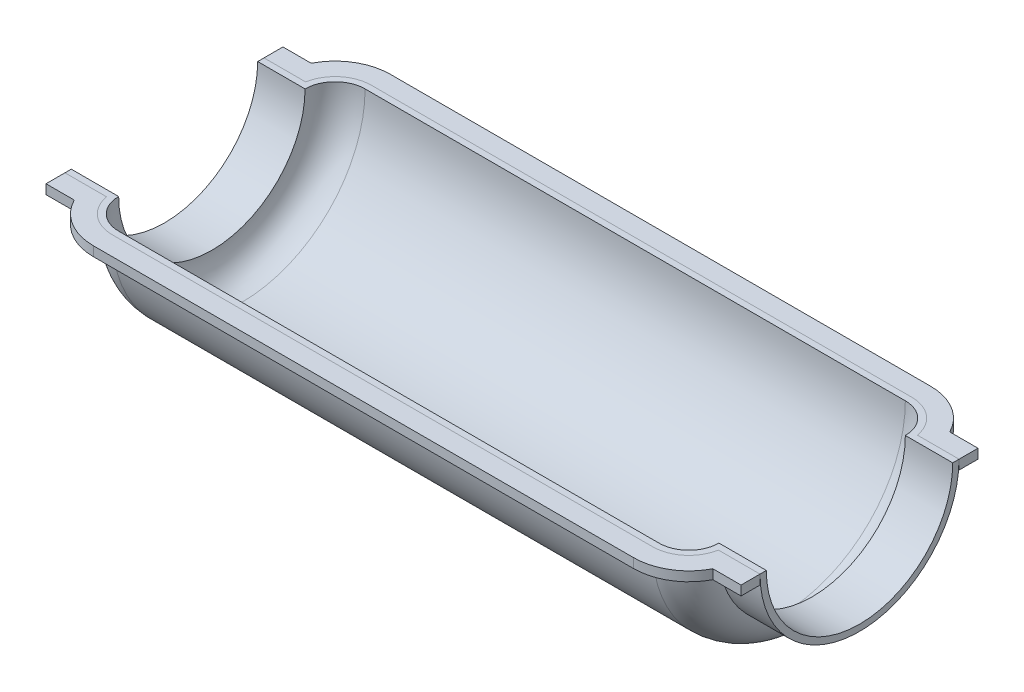
from build123d import *

# Parameters (mm, degrees)
REVOLVE1_ANGLE        = 180
BOSS_EXTRUDE1_DEPTH   = 3
BOSS_EXTRUDE1_2_DEPTH = 3


with BuildPart() as part:
    # Sketch1 → Revolve1 (revolve)
    with BuildSketch(Plane(origin=(0, 0, 0), x_dir=(1, 0, 0), z_dir=(0, 1, 0))):
        with BuildLine():
            Line((-110, 29.5), (-95, 29.5))
            ThreePointArc((-95, 29.5), (-92.217514421, 36.217514421), (-85.5, 39))
            Line((-85.5, 39), (85.5, 39))
            ThreePointArc((85.5, 39), (92.217514421, 36.217514421), (95, 29.5))
            Line((95, 29.5), (110, 29.5))
            Line((110, 29.5), (110, 31.5))
            Line((110, 31.5), (96.824751653, 31.5))
            ThreePointArc((96.824751653, 31.5), (92.89087275, 38.310505093), (85.5, 41))
            Line((85.5, 41), (-85.5, 41))
            ThreePointArc((-85.5, 41), (-92.89087275, 38.310505093), (-96.824751653, 31.5))
            Line((-96.824751653, 31.5), (-110, 31.5))
            Line((-110, 31.5), (-110, 29.5))
        make_face()
    revolve(axis=Axis((0, 0, 0), (-1, 0, 0)), revolution_arc=REVOLVE1_ANGLE)


with BuildPart() as body_2:
    # Sketch2 → Boss-Extrude1 (new body)
    with BuildSketch(Plane(origin=(0, 0, 0), x_dir=(1, 0, 0), z_dir=(0, 1, 0))):
        with BuildLine():
            Line((-96.824751653, 31.5), (-110, 31.5))
            Line((-110, 31.5), (-110, 37.5))
            Line((-110, 37.5), (-101.064382416, 37.5))
            ThreePointArc((-101.064382416, 37.5), (-94.617291264, 44.437369246), (-85.5, 47))
            Line((-85.5, 47), (85.5, 47))
            ThreePointArc((85.5, 47), (94.617291264, 44.437369246), (101.064382416, 37.5))
            Line((101.064382416, 37.5), (110, 37.5))
            Line((110, 37.5), (110, 31.5))
            Line((110, 31.5), (96.824751653, 31.5))
            ThreePointArc((96.824751653, 31.5), (92.89087275, 38.310505093), (85.5, 41))
            Line((85.5, 41), (-85.5, 41))
            ThreePointArc((-85.5, 41), (-92.89087275, 38.310505093), (-96.824751653, 31.5))
        make_face()
    extrude(amount=-BOSS_EXTRUDE1_DEPTH)


with BuildPart() as body_3:
    # Sketch2 → Boss-Extrude1 2 (new body)
    with BuildSketch(Plane(origin=(0, 0, 0), x_dir=(1, 0, 0), z_dir=(0, 1, 0))):
        with BuildLine():
            Line((110, -37.5), (110, -31.5))
            Line((110, -31.5), (96.824751653, -31.5))
            ThreePointArc((96.824751653, -31.5), (92.89087275, -38.310505093), (85.5, -41))
            Line((85.5, -41), (-85.5, -41))
            ThreePointArc((-85.5, -41), (-92.89087275, -38.310505093), (-96.824751653, -31.5))
            Line((-96.824751653, -31.5), (-110, -31.5))
            Line((-110, -31.5), (-110, -37.5))
            Line((-110, -37.5), (-101.064382416, -37.5))
            ThreePointArc((-101.064382416, -37.5), (-94.617291264, -44.437369246), (-85.5, -47))
            Line((-85.5, -47), (85.5, -47))
            ThreePointArc((85.5, -47), (94.617291264, -44.437369246), (101.064382416, -37.5))
            Line((101.064382416, -37.5), (110, -37.5))
        make_face()
    extrude(amount=-BOSS_EXTRUDE1_2_DEPTH)


solid = Compound([part.part, body_2.part, body_3.part])
